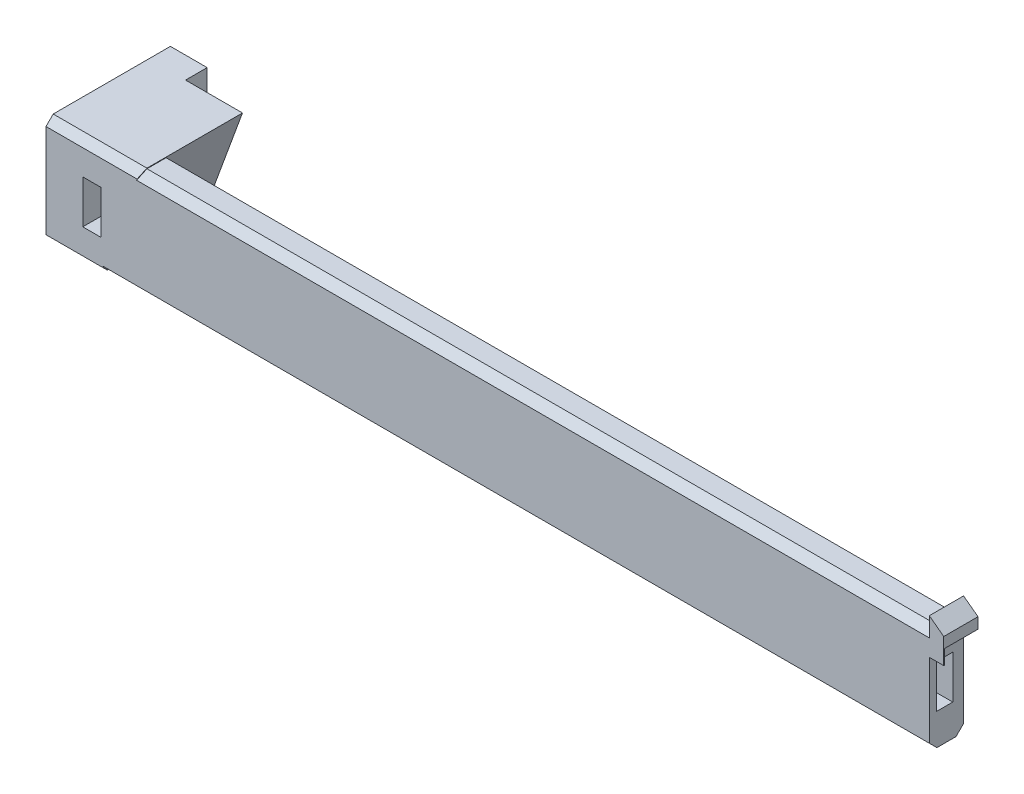
from build123d import *

# Parameters (mm, degrees)
SKETCH6_W                = 230
SKETCH6_H                = 30
BOSS_EXTRUDE1_DEPTH      = 9.5
BOSS_EXTRUDE2_DEPTH      = 9.5
BOSS_EXTRUDE2_DEPTH_BACK = 25
SKETCH12_R               = 6.5
CUT_EXTRUDE2_DEPTH       = 2
SKETCH15_R               = 6.5
CUT_EXTRUDE3_DEPTH       = 2
CUT_EXTRUDE4_DEPTH       = 6
SKETCH9_W                = 4.5
SKETCH9_H                = 12
CUT_EXTRUDE5_DEPTH       = 231
SKETCH17_W               = 5
SKETCH17_H               = 12
CUT_EXTRUDE6_DEPTH       = 29.5
SKETCH13_R               = 1.75
CUT_EXTRUDE8_DEPTH       = 16
SKETCH19_W               = 3
SKETCH19_H               = 5.6
CUT_EXTRUDE9_DEPTH       = 10
SKETCH20_W               = 4
SKETCH20_H               = 4
BOSS_EXTRUDE3_DEPTH      = 9.5
SKETCH20_3_W             = 25
SKETCH20_3_H             = 4
SKETCH20_3_W_2           = 4
CUT_EXTRUDE10_DEPTH      = 9.3
CUT_EXTRUDE11_DEPTH      = 10.5
CHAMFER2_SIZE            = 2.1
CHAMFER3_SIZE            = 2


with BuildPart() as part:
    # Sketch6 → Boss-Extrude1 (new body)
    with BuildSketch(Plane.XY):
        with Locations((-184.090144231, 89)):
            Rectangle(SKETCH6_W, SKETCH6_H)
    extrude(amount=BOSS_EXTRUDE1_DEPTH)

    # Sketch11 → Boss-Extrude2 (add, two sides)
    with BuildSketch(Plane.XY) as boss_extrude2_sk:
        Polygon((-299.090144231, 74), (-288.092548077, 104), (-314.090144231, 104), (-314.090144231, 74), align=None)
    extrude(amount=BOSS_EXTRUDE2_DEPTH)
    extrude(boss_extrude2_sk.sketch, amount=-BOSS_EXTRUDE2_DEPTH_BACK)

    # Sketch12 → Cut-Extrude2 (cut)
    with BuildSketch(Plane.ZY.offset(314.090144231)):
        with Locations((1.5, 89)):
            Circle(SKETCH12_R)
    extrude(amount=-CUT_EXTRUDE2_DEPTH, mode=Mode.SUBTRACT)

    # Sketch15 → Cut-Extrude3 (cut)
    with BuildSketch(Plane(origin=(0, 0, 0), x_dir=(-1, 0, 0), z_dir=(0, 0, -1))):
        with Locations((158.090144231, 89)):
            Circle(SKETCH15_R)
    extrude(amount=-CUT_EXTRUDE3_DEPTH, mode=Mode.SUBTRACT)

    # Sketch16 → Cut-Extrude4 (cut)
    with BuildSketch(Plane(origin=(0, 0, -25), x_dir=(-1, 0, 0), z_dir=(0, 0, -1))):
        Polygon((303.890144231, 74), (303.890144231, 104), (288.092548077, 104), (299.090144231, 74), align=None)
    extrude(amount=-CUT_EXTRUDE4_DEPTH, mode=Mode.SUBTRACT)

    # Sketch9 → Cut-Extrude5 (cut, through all)
    with BuildSketch(Plane.ZY.offset(299.090144231)):
        with Locations((5.25, 89)):
            Rectangle(SKETCH9_W, SKETCH9_H)
    extrude(amount=-CUT_EXTRUDE5_DEPTH, mode=Mode.SUBTRACT)

    # Sketch17 → Cut-Extrude6 (cut, through all)
    with BuildSketch(Plane(origin=(0, 0, -19), x_dir=(-1, 0, 0), z_dir=(0, 0, -1))):
        with Locations((301.390144231, 89)):
            Rectangle(SKETCH17_W, SKETCH17_H)
    extrude(amount=-CUT_EXTRUDE6_DEPTH, mode=Mode.SUBTRACT)

    # Sketch13 → Cut-Extrude8 (cut)
    with BuildSketch(Plane(origin=(0, 0, -25), x_dir=(-1, 0, 0), z_dir=(0, 0, -1))):
        with Locations((307.640144231, 79)):
            Circle(SKETCH13_R)
        with Locations((307.640144231, 99)):
            Circle(SKETCH13_R)
    extrude(amount=-CUT_EXTRUDE8_DEPTH, mode=Mode.SUBTRACT)

    # Sketch19 → Cut-Extrude9 (cut)
    with BuildSketch(Plane.ZY.offset(314.090144231)):
        with Locations((-14.5, 79)):
            Rectangle(SKETCH19_W, SKETCH19_H)
        with Locations((-14.5, 99)):
            Rectangle(SKETCH19_W, SKETCH19_H)
    extrude(amount=-CUT_EXTRUDE9_DEPTH, mode=Mode.SUBTRACT)

    # Sketch20 → Boss-Extrude3 (add)
    with BuildSketch(Plane(origin=(0, 0, 0), x_dir=(-1, 0, 0), z_dir=(0, 0, -1))):
        Polygon((69.090144231, 101), (69.090144231, 104), (69.090144231, 107), (65.090144231, 104), (65.090144231, 101), align=None)
        with Locations((67.090144231, 99)):
            Rectangle(SKETCH20_W, SKETCH20_H)
    extrude(amount=-BOSS_EXTRUDE3_DEPTH)

    # Sketch20_3 → Cut-Extrude10 (cut)
    with BuildSketch(Plane(origin=(0, 0, 0), x_dir=(-1, 0, 0), z_dir=(0, 0, -1))):
        with Locations((81.590144231, 99)):
            Rectangle(SKETCH20_3_W, SKETCH20_3_H)
        with Locations((67.090144231, 99)):
            Rectangle(SKETCH20_3_W_2, SKETCH20_3_H)
    extrude(amount=-CUT_EXTRUDE10_DEPTH, mode=Mode.SUBTRACT)

    # Sketch21 → Cut-Extrude11 (cut, through all)
    with BuildSketch(Plane(origin=(0, 0, 0), x_dir=(-1, 0, 0), z_dir=(0, 0, -1))):
        Polygon((288.092548077, 104), (288.184194712, 103.75), (69.090144231, 103.75), (69.090144231, 104), align=None)
        Polygon((299.090144231, 74), (69.090144231, 74), (69.090144231, 74.25), (298.998497596, 74.25), align=None)
    extrude(amount=-CUT_EXTRUDE11_DEPTH, mode=Mode.SUBTRACT)

    # Chamfer2
    chamfer2_edges = [part.edges().sort_by_distance(p)[0] for p in [
        (-178.637169471, 103.75, 9.5),
        (-178.637169471, 103.75, 0),
        (-184.044320913, 74.25, 9.5),
        (-184.044320913, 74.25, 0),
    ]]
    chamfer(chamfer2_edges, length=CHAMFER2_SIZE)

    # Chamfer3
    chamfer3_edges = [part.edges().sort_by_distance(p)[0] for p in [
        (-301.091346154, 104, 9.5),
        (-306.590144231, 74, 9.5),
    ]]
    chamfer(chamfer3_edges, length=CHAMFER3_SIZE)


solid = part.part
